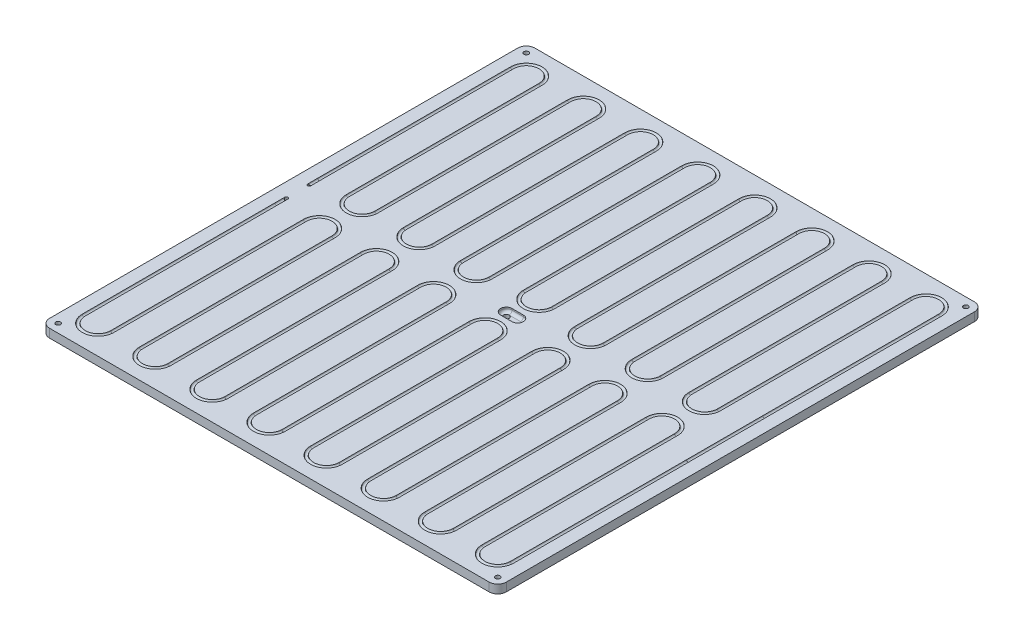
from build123d import *

# Parameters (mm, degrees)
EXTRUDE_1_DEPTH     = 6
CUT_EXTRUDE_1_DEPTH = 3
FILLET_4_R          = 2
SKETCH_3_R          = 1.1
SKETCH_5_R          = 1.65
SKETCH_5_R_2        = 2
SKETCH_5_R_3        = 1.102033545
SKETCH_5_R_4        = 1.103291211
CUT_EXTRUDE_2_DEPTH = 7


with BuildPart() as part:
    # Эскиз1 → Бобышка-Вытянуть1 (new body)
    with BuildSketch(Plane(origin=(0, 0, 0), x_dir=(1, 0, 0), z_dir=(0, 1, 0))):
        with BuildLine():
            Line((-154, -156), (154, -156))
            ThreePointArc((154, -156), (158.242640687, -154.242640687), (160, -150))
            Line((160, -150), (160, 178))
            ThreePointArc((160, 178), (158.242640687, 182.242640687), (154, 184))
            Line((154, 184), (-154, 184))
            ThreePointArc((-154, 184), (-158.242640687, 182.242640687), (-160, 178))
            Line((-160, 178), (-160, -150))
            ThreePointArc((-160, -150), (-158.242640687, -154.242640687), (-154, -156))
        make_face()
    extrude(amount=EXTRUDE_1_DEPTH)

    # Эскиз4 → Вырез-Вытянуть1 (cut)
    with BuildSketch(Plane(origin=(0, 6, 0), x_dir=(1, 0, 0), z_dir=(0, 1, 0))):
        with BuildLine():
            Line((-4, 18), (4, 18))
            ThreePointArc((4, 18), (8, 14), (4, 10))
            Line((4, 10), (-4, 10))
            ThreePointArc((-4, 10), (-8, 14), (-4, 18))
        make_face()
    extrude(amount=-CUT_EXTRUDE_1_DEPTH, mode=Mode.SUBTRACT)

    # Скругление4
    fillet_4_edges = [part.edges().sort_by_distance(p)[0] for p in [
        (-8, 3, -14),
        (0, 3, -18),
        (8, 3, -14),
        (0, 3, -10),
    ]]
    fillet(fillet_4_edges, radius=FILLET_4_R)

    # Вырез-По траектории1: sweep along a path in Эскиз2
    with BuildLine(Plane(origin=(0, 6, 0), x_dir=(1, 0, 0), z_dir=(0, 1, 0))) as sweep_1_path:
        Line((-150, 22), (-150, 29))
        Line((-150, 29), (-150, 164))
        ThreePointArc((-150, 164), (-140, 174), (-130, 164))
        Line((-130, 164), (-130, 29))
        ThreePointArc((-130, 29), (-120, 19), (-110, 29))
        Line((-110, 29), (-110, 164))
        ThreePointArc((-110, 164), (-100, 174), (-90, 164))
        Line((-90, 164), (-90, 29))
        ThreePointArc((-90, 29), (-80, 19), (-70, 29))
        Line((-70, 29), (-70, 164))
        ThreePointArc((-70, 164), (-60, 174), (-50, 164))
        Line((-50, 164), (-50, 29))
        ThreePointArc((-50, 29), (-40, 19), (-30, 29))
        Line((-30, 29), (-30, 164))
        ThreePointArc((-30, 164), (-20, 174), (-10, 164))
        Line((-10, 164), (-10, 33))
        ThreePointArc((-10, 33), (0, 23), (10, 33))
        Line((10, 33), (10, 164))
        ThreePointArc((10, 164), (20, 174), (30, 164))
        Line((30, 164), (30, 29))
        ThreePointArc((30, 29), (40, 19), (50, 29))
        Line((50, 29), (50, 164))
        ThreePointArc((50, 164), (60, 174), (70, 164))
        Line((70, 164), (70, 29))
        ThreePointArc((70, 29), (80, 19), (90, 29))
        Line((90, 29), (90, 164))
        ThreePointArc((90, 164), (100, 174), (110, 164))
        Line((110, 164), (110, 29))
        ThreePointArc((110, 29), (120, 19), (130, 29))
        Line((130, 29), (130, 164))
        ThreePointArc((130, 164), (140, 174), (150, 164))
        Line((150, 164), (150, 40.647058824))
        Line((150, 40.647058824), (150, -12.647058824))
        Line((150, -12.647058824), (150, -136))
        ThreePointArc((150, -136), (140, -146), (130, -136))
        Line((130, -136), (130, -1))
        ThreePointArc((130, -1), (120, 9), (110, -1))
        Line((110, -1), (110, -136))
        ThreePointArc((110, -136), (100, -146), (90, -136))
        Line((90, -136), (90, -1))
        ThreePointArc((90, -1), (80, 9), (70, -1))
        Line((70, -1), (70, -136))
        ThreePointArc((70, -136), (60, -146), (50, -136))
        Line((50, -136), (50, -1))
        ThreePointArc((50, -1), (40, 9), (30, -1))
        Line((30, -1), (30, -136))
        ThreePointArc((30, -136), (20, -146), (10, -136))
        Line((10, -136), (10, -5))
        ThreePointArc((10, -5), (0, 5), (-10, -5))
        Line((-10, -5), (-10, -136))
        ThreePointArc((-10, -136), (-20, -146), (-30, -136))
        Line((-30, -136), (-30, -1))
        ThreePointArc((-30, -1), (-40, 9), (-50, -1))
        Line((-50, -1), (-50, -136))
        ThreePointArc((-50, -136), (-60, -146), (-70, -136))
        Line((-70, -136), (-70, -1))
        ThreePointArc((-70, -1), (-80, 9), (-90, -1))
        Line((-90, -1), (-90, -136))
        ThreePointArc((-90, -136), (-100, -146), (-110, -136))
        Line((-110, -136), (-110, -1))
        ThreePointArc((-110, -1), (-120, 9), (-130, -1))
        Line((-130, -1), (-130, -136))
        ThreePointArc((-130, -136), (-140, -146), (-150, -136))
        Line((-150, -136), (-150, -1))
        Line((-150, -1), (-150, 6))
    # Эскиз3 → Вырез-По траектории1 (sweep, cut)
    with BuildSketch(Plane.XY.offset(-22)):
        with Locations((-150, 6)):
            Circle(SKETCH_3_R)
    sweep(path=sweep_1_path.line, mode=Mode.SUBTRACT)

    # Эскиз5 → Вырез-Вытянуть2 (cut, through all)
    with BuildSketch(Plane(origin=(0, 6, 0), x_dir=(1, 0, 0), z_dir=(0, 1, 0))):
        with Locations((-154, 178)):
            Circle(SKETCH_5_R)
        with Locations((154, 178)):
            Circle(SKETCH_5_R)
        with Locations((154, -150)):
            Circle(SKETCH_5_R)
        with Locations((-154, -150)):
            Circle(SKETCH_5_R)
        with Locations((-4, 14)):
            Circle(SKETCH_5_R_2)
        with Locations((-150, 22)):
            Circle(SKETCH_5_R_3)
        with Locations((-150, 6)):
            Circle(SKETCH_5_R_4)
    extrude(amount=-CUT_EXTRUDE_2_DEPTH, mode=Mode.SUBTRACT)


solid = part.part
